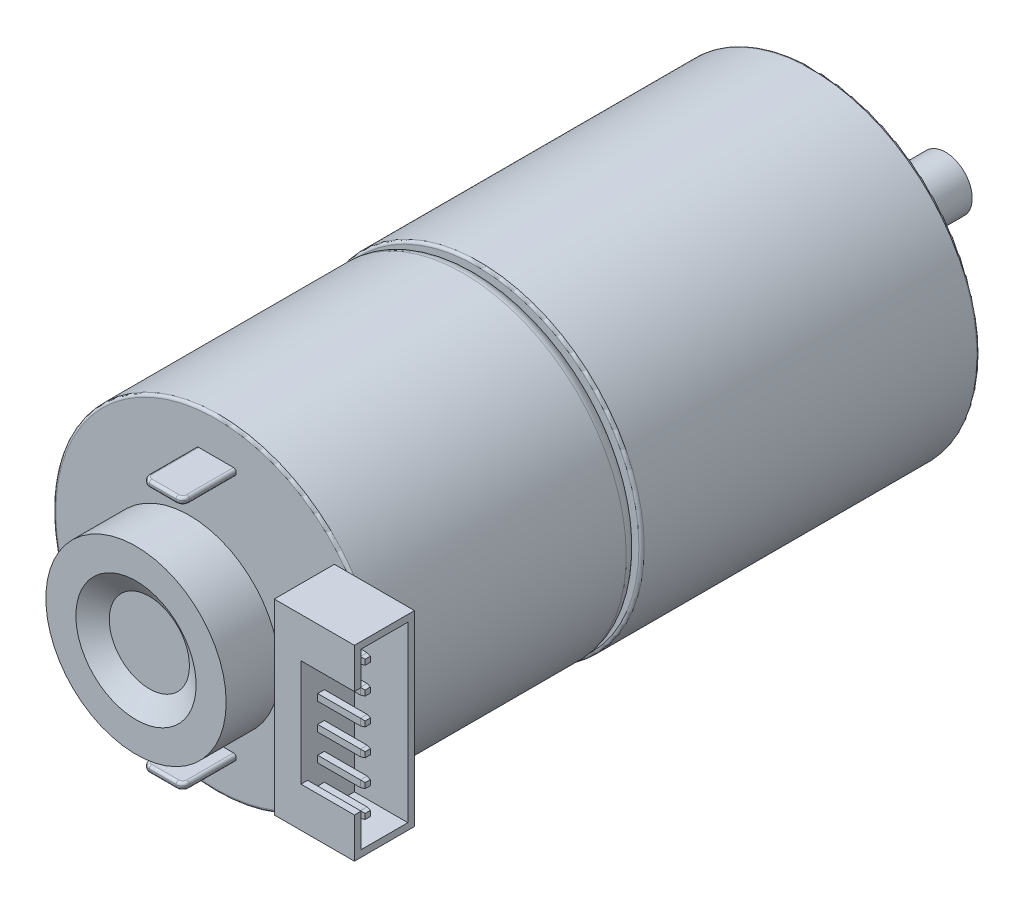
from build123d import *

# Parameters (mm, degrees)
SKETCH1_R              = 12.35
BOSS_EXTRUDE1_DEPTH    = 25.3
SKETCH3_R              = 1
BOSS_EXTRUDE2_DEPTH    = 6
SKETCH4_W              = 3
SKETCH4_H              = 0.5
BOSS_EXTRUDE3_DEPTH    = 4
FILLET2_R              = 0.5
FILLET3_R              = 0.2
SKETCH5_R              = 3.5
BOSS_EXTRUDE4_DEPTH    = 2.5
FILLET4_R              = 0.2
BOSS_EXTRUDE5_DEPTH    = 7.3
M3_TAPPED_HOLE1_D      = 2.5
M3_TAPPED_HOLE1_DEPTH  = 7.5
M3_TAPPED_HOLE1_TIP    = 0.751075774
SKETCH9_R              = 6.75
BOSS_EXTRUDE6_DEPTH    = 4
SKETCH10_W             = 6
SKETCH10_H             = 14
BOSS_EXTRUDE7_DEPTH    = 4.5
SKETCH11_W             = 3.5
SKETCH11_H             = 13
CUT_EXTRUDE1_DEPTH     = 4
SKETCH12_W             = 4
SKETCH12_H             = 8
CUT_EXTRUDE2_DEPTH     = 2.5
SKETCH13_W             = 0.5
SKETCH13_H             = 0.5
BOSS_EXTRUDE8_DEPTH    = 3.5
CHAMFER1_SIZE          = 0.3
CHAMFER1_SIZE2         = 0.052898094
CHAMFER1_PART_2_SIZE   = 0.3
CHAMFER1_PART_2_SIZE2  = 0.052898094
CHAMFER1_PART_3_SIZE   = 0.3
CHAMFER1_PART_3_SIZE2  = 0.052898094
CHAMFER1_PART_4_SIZE   = 0.3
CHAMFER1_PART_4_SIZE2  = 0.052898094
CHAMFER1_PART_5_SIZE   = 0.3
CHAMFER1_PART_5_SIZE2  = 0.052898094
CHAMFER1_PART_6_SIZE   = 0.3
CHAMFER1_PART_6_SIZE2  = 0.052898094
CHAMFER1_PART_7_SIZE   = 0.3
CHAMFER1_PART_7_SIZE2  = 0.052898094
CHAMFER1_PART_8_SIZE   = 0.3
CHAMFER1_PART_8_SIZE2  = 0.052898094
CHAMFER1_PART_9_SIZE   = 0.3
CHAMFER1_PART_9_SIZE2  = 0.052898094
CHAMFER1_PART_10_SIZE  = 0.3
CHAMFER1_PART_10_SIZE2 = 0.052898094
CHAMFER1_PART_11_SIZE  = 0.3
CHAMFER1_PART_11_SIZE2 = 0.052898094
CHAMFER1_PART_12_SIZE  = 0.3
CHAMFER1_PART_12_SIZE2 = 0.052898094
CHAMFER1_PART_13_SIZE  = 0.3
CHAMFER1_PART_13_SIZE2 = 0.052898094
CHAMFER1_PART_14_SIZE  = 0.3
CHAMFER1_PART_14_SIZE2 = 0.052898094
CHAMFER1_PART_15_SIZE  = 0.3
CHAMFER1_PART_15_SIZE2 = 0.052898094
CHAMFER1_PART_16_SIZE  = 0.3
CHAMFER1_PART_16_SIZE2 = 0.052898094
CHAMFER1_PART_17_SIZE  = 0.3
CHAMFER1_PART_17_SIZE2 = 0.052898094
CHAMFER1_PART_18_SIZE  = 0.3
CHAMFER1_PART_18_SIZE2 = 0.052898094
CHAMFER1_PART_19_SIZE  = 0.3
CHAMFER1_PART_19_SIZE2 = 0.052898094
CHAMFER1_PART_20_SIZE  = 0.3
CHAMFER1_PART_20_SIZE2 = 0.052898094
CHAMFER1_PART_21_SIZE  = 0.3
CHAMFER1_PART_21_SIZE2 = 0.052898094
CHAMFER1_PART_22_SIZE  = 0.3
CHAMFER1_PART_22_SIZE2 = 0.052898094
CHAMFER1_PART_23_SIZE  = 0.3
CHAMFER1_PART_23_SIZE2 = 0.052898094
CHAMFER1_PART_24_SIZE  = 0.3
CHAMFER1_PART_24_SIZE2 = 0.052898094


with BuildPart() as part:
    # Sketch1 → Boss-Extrude1 (new body)
    with BuildSketch(Plane.XY):
        Circle(SKETCH1_R)
    extrude(amount=BOSS_EXTRUDE1_DEPTH)

    # Sketch2 → Revolve1 (revolve)
    with BuildSketch(Plane(origin=(0, 0, 0), x_dir=(0, 0, -1), z_dir=(1, 0, 0))):
        with BuildLine():
            Line((-25.3, 0), (-44.8, 0))
            Line((-44.8, 0), (-44.8, 12.2))
            Line((-44.8, 12.2), (-26.3, 12.2))
            ThreePointArc((-26.3, 12.2), (-25.592893219, 11.907106781), (-25.3, 11.2))
            Line((-25.3, 11.2), (-25.3, 0))
        make_face()
    revolve(axis=Axis((0, 0, 25.3), (0, 0, 1)))

    # Sketch3 → Boss-Extrude2 (add)
    with BuildSketch(Plane.XY.offset(44.8)):
        Circle(SKETCH3_R)
    extrude(amount=BOSS_EXTRUDE2_DEPTH)

    # Sketch4 → Boss-Extrude3 (add)
    with BuildSketch(Plane.XY.offset(44.8)):
        with Locations((0, 9.25)):
            Rectangle(SKETCH4_W, SKETCH4_H)
        with Locations((0, -9.25)):
            Rectangle(SKETCH4_W, SKETCH4_H)
    extrude(amount=BOSS_EXTRUDE3_DEPTH)

    # Fillet2
    fillet2_edges = [part.edges().sort_by_distance(p)[0] for p in [
        (1.5, -9.25, 48.8),
        (-1.5, -9.25, 48.8),
        (-1.5, 9.25, 48.8),
        (1.5, 9.25, 48.8),
    ]]
    fillet(fillet2_edges, radius=FILLET2_R)

    # Fillet3
    fillet3_edges = [part.edges().sort_by_distance(p)[0] for p in [
        (-12.35, 0, 0),
        (0, 9, 48.8),
        (0, 9.5, 48.8),
        (-12.35, 0, 25.3),
        (1.5, 9, 46.55),
        (-1.5, 9, 46.55),
        (1.353553391, 9, 48.653553391),
        (-1.353553391, 9, 48.653553391),
        (-1.5, 9.5, 46.55),
        (1.5, 9.5, 46.55),
        (1.353553391, 9.5, 48.653553391),
        (-1.353553391, 9.5, 48.653553391),
        (0, -9, 48.8),
        (0, -9.5, 48.8),
        (1.5, -9.5, 46.55),
        (-1.5, -9.5, 46.55),
        (1.353553391, -9.5, 48.653553391),
        (-1.353553391, -9.5, 48.653553391),
        (-1.5, -9, 46.55),
        (1.5, -9, 46.55),
        (1.353553391, -9, 48.653553391),
        (-1.353553391, -9, 48.653553391),
        (0, -12.2, 44.8),
    ]]
    fillet(fillet3_edges, radius=FILLET3_R)

    # Sketch5 → Boss-Extrude4 (add)
    with BuildSketch(Plane(origin=(0, 0, 0), x_dir=(-1, 0, 0), z_dir=(0, 0, -1))):
        Circle(SKETCH5_R)
    extrude(amount=BOSS_EXTRUDE4_DEPTH)

    # Fillet4
    fillet4_edges = [part.edges().sort_by_distance(p)[0] for p in [
        (3.5, 0, -2.5),
    ]]
    fillet(fillet4_edges, radius=FILLET4_R)

    # Sketch6 → Boss-Extrude5 (add)
    with BuildSketch(Plane(origin=(0, 0, -2.5), x_dir=(-1, 0, 0), z_dir=(0, 0, -1))):
        with BuildLine():
            Line((1.322875656, -1.5), (-1.322875656, -1.5))
            ThreePointArc((-1.322875656, -1.5), (0, 2), (1.322875656, -1.5))
        make_face()
    extrude(amount=BOSS_EXTRUDE5_DEPTH)

    # M3 Tapped Hole1
    with Locations(Plane(origin=(0, -8.5, 0), x_dir=(-1, 0, 0), z_dir=(0, 0, -1))):
        with Locations((0, 0), (0, 17)):
            Hole(M3_TAPPED_HOLE1_D / 2, depth=M3_TAPPED_HOLE1_DEPTH)
            with Locations((0, 0, -(M3_TAPPED_HOLE1_DEPTH + M3_TAPPED_HOLE1_TIP / 2))):  # 118° drill point
                Cone(0, M3_TAPPED_HOLE1_D / 2, M3_TAPPED_HOLE1_TIP, mode=Mode.SUBTRACT)

    # Sketch9 → Boss-Extrude6 (add)
    with BuildSketch(Plane.XY.offset(50.8)):
        Circle(SKETCH9_R)
    extrude(amount=-BOSS_EXTRUDE6_DEPTH)

    # Sketch10 → Boss-Extrude7 (add)
    with BuildSketch(Plane.XY.offset(44.8)):
        with Locations((11.85, 0)):
            Rectangle(SKETCH10_W, SKETCH10_H)
    extrude(amount=BOSS_EXTRUDE7_DEPTH)

    # Sketch11 → Cut-Extrude1 (cut)
    with BuildSketch(Plane(origin=(14.85, 0, 0), x_dir=(0, 0, -1), z_dir=(1, 0, 0))):
        with Locations((-47.05, 0)):
            Rectangle(SKETCH11_W, SKETCH11_H)
    extrude(amount=-CUT_EXTRUDE1_DEPTH, mode=Mode.SUBTRACT)

    # Sketch12 → Cut-Extrude2 (cut)
    with BuildSketch(Plane.XY.offset(49.3)):
        with Locations((12.85, 0)):
            Rectangle(SKETCH12_W, SKETCH12_H)
    extrude(amount=-CUT_EXTRUDE2_DEPTH, mode=Mode.SUBTRACT)

    # Sketch13 → Boss-Extrude8 (add)
    with BuildSketch(Plane(origin=(10.85, 0, 0), x_dir=(0, 0, -1), z_dir=(1, 0, 0))):
        with Locations((-47.8, -5)):
            Rectangle(SKETCH13_W, SKETCH13_H)
        with Locations((-47.8, -3)):
            Rectangle(SKETCH13_W, SKETCH13_H)
        with Locations((-47.8, -1)):
            Rectangle(SKETCH13_W, SKETCH13_H)
        with Locations((-47.8, 1)):
            Rectangle(SKETCH13_W, SKETCH13_H)
        with Locations((-47.8, 3)):
            Rectangle(SKETCH13_W, SKETCH13_H)
        with Locations((-47.8, 5)):
            Rectangle(SKETCH13_W, SKETCH13_H)
    extrude(amount=BOSS_EXTRUDE8_DEPTH)

    # Chamfer1
    chamfer1_edges = [part.edges().sort_by_distance(p)[0] for p in [
        (14.35, -5, 47.55),
    ]]
    chamfer1_side = [part.faces().sort_by_distance(p)[0] for p in [
        (12.6, -5, 47.55),
    ]]
    chamfer(chamfer1_edges, length=CHAMFER1_SIZE, length2=CHAMFER1_SIZE2, reference=chamfer1_side[0])

    # Chamfer1 part 2
    chamfer1_part_2_edges = [part.edges().sort_by_distance(p)[0] for p in [
        (14.35, -4.75, 47.8),
    ]]
    chamfer1_part_2_side = [part.faces().sort_by_distance(p)[0] for p in [
        (12.6, -4.75, 47.8),
    ]]
    chamfer(chamfer1_part_2_edges, length=CHAMFER1_PART_2_SIZE, length2=CHAMFER1_PART_2_SIZE2, reference=chamfer1_part_2_side[0])

    # Chamfer1 part 3
    chamfer1_part_3_edges = [part.edges().sort_by_distance(p)[0] for p in [
        (14.35, -5, 48.05),
    ]]
    chamfer1_part_3_side = [part.faces().sort_by_distance(p)[0] for p in [
        (12.6, -5, 48.05),
    ]]
    chamfer(chamfer1_part_3_edges, length=CHAMFER1_PART_3_SIZE, length2=CHAMFER1_PART_3_SIZE2, reference=chamfer1_part_3_side[0])

    # Chamfer1 part 4
    chamfer1_part_4_edges = [part.edges().sort_by_distance(p)[0] for p in [
        (14.35, -5.25, 47.8),
    ]]
    chamfer1_part_4_side = [part.faces().sort_by_distance(p)[0] for p in [
        (12.6, -5.25, 47.8),
    ]]
    chamfer(chamfer1_part_4_edges, length=CHAMFER1_PART_4_SIZE, length2=CHAMFER1_PART_4_SIZE2, reference=chamfer1_part_4_side[0])

    # Chamfer1 part 5
    chamfer1_part_5_edges = [part.edges().sort_by_distance(p)[0] for p in [
        (14.35, -3, 47.55),
    ]]
    chamfer1_part_5_side = [part.faces().sort_by_distance(p)[0] for p in [
        (12.6, -3, 47.55),
    ]]
    chamfer(chamfer1_part_5_edges, length=CHAMFER1_PART_5_SIZE, length2=CHAMFER1_PART_5_SIZE2, reference=chamfer1_part_5_side[0])

    # Chamfer1 part 6
    chamfer1_part_6_edges = [part.edges().sort_by_distance(p)[0] for p in [
        (14.35, -2.75, 47.8),
    ]]
    chamfer1_part_6_side = [part.faces().sort_by_distance(p)[0] for p in [
        (12.6, -2.75, 47.8),
    ]]
    chamfer(chamfer1_part_6_edges, length=CHAMFER1_PART_6_SIZE, length2=CHAMFER1_PART_6_SIZE2, reference=chamfer1_part_6_side[0])

    # Chamfer1 part 7
    chamfer1_part_7_edges = [part.edges().sort_by_distance(p)[0] for p in [
        (14.35, -3, 48.05),
    ]]
    chamfer1_part_7_side = [part.faces().sort_by_distance(p)[0] for p in [
        (12.6, -3, 48.05),
    ]]
    chamfer(chamfer1_part_7_edges, length=CHAMFER1_PART_7_SIZE, length2=CHAMFER1_PART_7_SIZE2, reference=chamfer1_part_7_side[0])

    # Chamfer1 part 8
    chamfer1_part_8_edges = [part.edges().sort_by_distance(p)[0] for p in [
        (14.35, -3.25, 47.8),
    ]]
    chamfer1_part_8_side = [part.faces().sort_by_distance(p)[0] for p in [
        (12.6, -3.25, 47.8),
    ]]
    chamfer(chamfer1_part_8_edges, length=CHAMFER1_PART_8_SIZE, length2=CHAMFER1_PART_8_SIZE2, reference=chamfer1_part_8_side[0])

    # Chamfer1 part 9
    chamfer1_part_9_edges = [part.edges().sort_by_distance(p)[0] for p in [
        (14.35, -1, 47.55),
    ]]
    chamfer1_part_9_side = [part.faces().sort_by_distance(p)[0] for p in [
        (12.6, -1, 47.55),
    ]]
    chamfer(chamfer1_part_9_edges, length=CHAMFER1_PART_9_SIZE, length2=CHAMFER1_PART_9_SIZE2, reference=chamfer1_part_9_side[0])

    # Chamfer1 part 10
    chamfer1_part_10_edges = [part.edges().sort_by_distance(p)[0] for p in [
        (14.35, -0.75, 47.8),
    ]]
    chamfer1_part_10_side = [part.faces().sort_by_distance(p)[0] for p in [
        (12.6, -0.75, 47.8),
    ]]
    chamfer(chamfer1_part_10_edges, length=CHAMFER1_PART_10_SIZE, length2=CHAMFER1_PART_10_SIZE2, reference=chamfer1_part_10_side[0])

    # Chamfer1 part 11
    chamfer1_part_11_edges = [part.edges().sort_by_distance(p)[0] for p in [
        (14.35, -1, 48.05),
    ]]
    chamfer1_part_11_side = [part.faces().sort_by_distance(p)[0] for p in [
        (12.6, -1, 48.05),
    ]]
    chamfer(chamfer1_part_11_edges, length=CHAMFER1_PART_11_SIZE, length2=CHAMFER1_PART_11_SIZE2, reference=chamfer1_part_11_side[0])

    # Chamfer1 part 12
    chamfer1_part_12_edges = [part.edges().sort_by_distance(p)[0] for p in [
        (14.35, -1.25, 47.8),
    ]]
    chamfer1_part_12_side = [part.faces().sort_by_distance(p)[0] for p in [
        (12.6, -1.25, 47.8),
    ]]
    chamfer(chamfer1_part_12_edges, length=CHAMFER1_PART_12_SIZE, length2=CHAMFER1_PART_12_SIZE2, reference=chamfer1_part_12_side[0])

    # Chamfer1 part 13
    chamfer1_part_13_edges = [part.edges().sort_by_distance(p)[0] for p in [
        (14.35, 1, 47.55),
    ]]
    chamfer1_part_13_side = [part.faces().sort_by_distance(p)[0] for p in [
        (12.6, 1, 47.55),
    ]]
    chamfer(chamfer1_part_13_edges, length=CHAMFER1_PART_13_SIZE, length2=CHAMFER1_PART_13_SIZE2, reference=chamfer1_part_13_side[0])

    # Chamfer1 part 14
    chamfer1_part_14_edges = [part.edges().sort_by_distance(p)[0] for p in [
        (14.35, 1.25, 47.8),
    ]]
    chamfer1_part_14_side = [part.faces().sort_by_distance(p)[0] for p in [
        (12.6, 1.25, 47.8),
    ]]
    chamfer(chamfer1_part_14_edges, length=CHAMFER1_PART_14_SIZE, length2=CHAMFER1_PART_14_SIZE2, reference=chamfer1_part_14_side[0])

    # Chamfer1 part 15
    chamfer1_part_15_edges = [part.edges().sort_by_distance(p)[0] for p in [
        (14.35, 1, 48.05),
    ]]
    chamfer1_part_15_side = [part.faces().sort_by_distance(p)[0] for p in [
        (12.6, 1, 48.05),
    ]]
    chamfer(chamfer1_part_15_edges, length=CHAMFER1_PART_15_SIZE, length2=CHAMFER1_PART_15_SIZE2, reference=chamfer1_part_15_side[0])

    # Chamfer1 part 16
    chamfer1_part_16_edges = [part.edges().sort_by_distance(p)[0] for p in [
        (14.35, 0.75, 47.8),
    ]]
    chamfer1_part_16_side = [part.faces().sort_by_distance(p)[0] for p in [
        (12.6, 0.75, 47.8),
    ]]
    chamfer(chamfer1_part_16_edges, length=CHAMFER1_PART_16_SIZE, length2=CHAMFER1_PART_16_SIZE2, reference=chamfer1_part_16_side[0])

    # Chamfer1 part 17
    chamfer1_part_17_edges = [part.edges().sort_by_distance(p)[0] for p in [
        (14.35, 3, 47.55),
    ]]
    chamfer1_part_17_side = [part.faces().sort_by_distance(p)[0] for p in [
        (12.6, 3, 47.55),
    ]]
    chamfer(chamfer1_part_17_edges, length=CHAMFER1_PART_17_SIZE, length2=CHAMFER1_PART_17_SIZE2, reference=chamfer1_part_17_side[0])

    # Chamfer1 part 18
    chamfer1_part_18_edges = [part.edges().sort_by_distance(p)[0] for p in [
        (14.35, 3.25, 47.8),
    ]]
    chamfer1_part_18_side = [part.faces().sort_by_distance(p)[0] for p in [
        (12.6, 3.25, 47.8),
    ]]
    chamfer(chamfer1_part_18_edges, length=CHAMFER1_PART_18_SIZE, length2=CHAMFER1_PART_18_SIZE2, reference=chamfer1_part_18_side[0])

    # Chamfer1 part 19
    chamfer1_part_19_edges = [part.edges().sort_by_distance(p)[0] for p in [
        (14.35, 3, 48.05),
    ]]
    chamfer1_part_19_side = [part.faces().sort_by_distance(p)[0] for p in [
        (12.6, 3, 48.05),
    ]]
    chamfer(chamfer1_part_19_edges, length=CHAMFER1_PART_19_SIZE, length2=CHAMFER1_PART_19_SIZE2, reference=chamfer1_part_19_side[0])

    # Chamfer1 part 20
    chamfer1_part_20_edges = [part.edges().sort_by_distance(p)[0] for p in [
        (14.35, 2.75, 47.8),
    ]]
    chamfer1_part_20_side = [part.faces().sort_by_distance(p)[0] for p in [
        (12.6, 2.75, 47.8),
    ]]
    chamfer(chamfer1_part_20_edges, length=CHAMFER1_PART_20_SIZE, length2=CHAMFER1_PART_20_SIZE2, reference=chamfer1_part_20_side[0])

    # Chamfer1 part 21
    chamfer1_part_21_edges = [part.edges().sort_by_distance(p)[0] for p in [
        (14.35, 5, 47.55),
    ]]
    chamfer1_part_21_side = [part.faces().sort_by_distance(p)[0] for p in [
        (12.6, 5, 47.55),
    ]]
    chamfer(chamfer1_part_21_edges, length=CHAMFER1_PART_21_SIZE, length2=CHAMFER1_PART_21_SIZE2, reference=chamfer1_part_21_side[0])

    # Chamfer1 part 22
    chamfer1_part_22_edges = [part.edges().sort_by_distance(p)[0] for p in [
        (14.35, 5.25, 47.8),
    ]]
    chamfer1_part_22_side = [part.faces().sort_by_distance(p)[0] for p in [
        (12.6, 5.25, 47.8),
    ]]
    chamfer(chamfer1_part_22_edges, length=CHAMFER1_PART_22_SIZE, length2=CHAMFER1_PART_22_SIZE2, reference=chamfer1_part_22_side[0])

    # Chamfer1 part 23
    chamfer1_part_23_edges = [part.edges().sort_by_distance(p)[0] for p in [
        (14.35, 5, 48.05),
    ]]
    chamfer1_part_23_side = [part.faces().sort_by_distance(p)[0] for p in [
        (12.6, 5, 48.05),
    ]]
    chamfer(chamfer1_part_23_edges, length=CHAMFER1_PART_23_SIZE, length2=CHAMFER1_PART_23_SIZE2, reference=chamfer1_part_23_side[0])

    # Chamfer1 part 24
    chamfer1_part_24_edges = [part.edges().sort_by_distance(p)[0] for p in [
        (14.35, 4.75, 47.8),
    ]]
    chamfer1_part_24_side = [part.faces().sort_by_distance(p)[0] for p in [
        (12.6, 4.75, 47.8),
    ]]
    chamfer(chamfer1_part_24_edges, length=CHAMFER1_PART_24_SIZE, length2=CHAMFER1_PART_24_SIZE2, reference=chamfer1_part_24_side[0])

    # Sketch14 → Cut-Revolve1 (revolve, cut)
    with BuildSketch(Plane(origin=(0, 0, 0), x_dir=(0, 0, -1), z_dir=(1, 0, 0))):
        Polygon((-49.8, 3), (-50.8, 4.5), (-50.8, 0), (-49.8, 0), align=None)
    revolve(axis=Axis((0, 0, 50.8), (0, 0, -1)), mode=Mode.SUBTRACT)


solid = part.part
